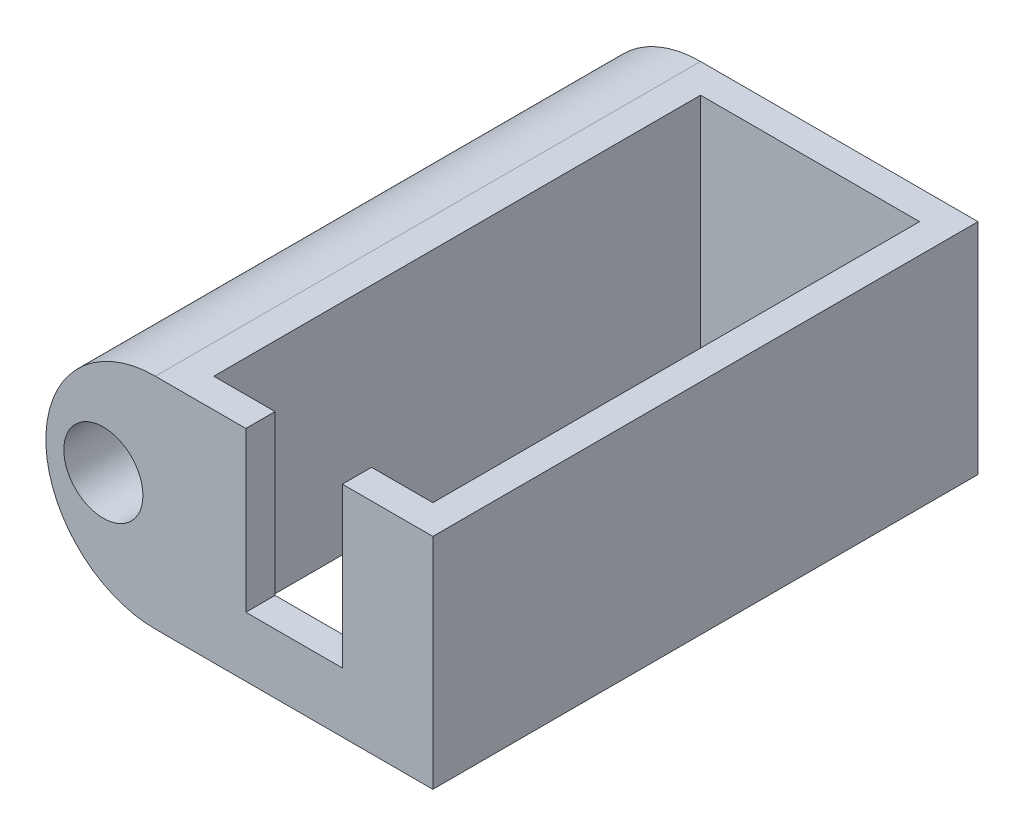
from build123d import *

# Parameters (mm, degrees)
SKETCH1_W           = 11.4
SKETCH1_H           = 22.4
SKETCH1_W_2         = 9
SKETCH1_H_2         = 20
BOSS_EXTRUDE1_DEPTH = 9
CUT_EXTRUDE1_REACH  = 24.4
SKETCH2_W           = 3.96584196
SKETCH2_H           = 6.540682608
SKETCH3_R           = 1.625
BOSS_EXTRUDE2_DEPTH = 22.4
CUT_EXTRUDE2_START  = -4
SKETCH4_R           = 1
CUT_EXTRUDE2_DEPTH  = 10
SKETCH5_R           = 1.55
SKETCH5_R_2         = 1.001932819
BOSS_EXTRUDE3_DEPTH = 1


with BuildPart() as part:
    # Sketch1 → Boss-Extrude1 (new body)
    with BuildSketch(Plane(origin=(0, 0, 0), x_dir=(1, 0, 0), z_dir=(0, 1, 0))):
        with Locations((4.5, 10)):
            Rectangle(SKETCH1_W, SKETCH1_H)
        with Locations((4.5, 10)):
            Rectangle(SKETCH1_W_2, SKETCH1_H_2, mode=Mode.SUBTRACT)
    extrude(amount=BOSS_EXTRUDE1_DEPTH)

    # Sketch2 → Cut-Extrude1 (cut, up to next)
    with BuildSketch(Plane.XY.offset(1.2), mode=Mode.PRIVATE) as cut_extrude1_sk1:
        with Locations((4.5, 5.729658696)):
            Rectangle(SKETCH2_W, SKETCH2_H)
    cut_extrude1_tool1 = extrude(cut_extrude1_sk1.sketch, amount=-CUT_EXTRUDE1_REACH, mode=Mode.PRIVATE) & part.part
    add(cut_extrude1_tool1.solids().sort_by_distance((4.5, 5.729659, 1.2))[0], mode=Mode.SUBTRACT)

    # Sketch3 → Boss-Extrude2 (add)
    with BuildSketch(Plane.XY.offset(1.2)):
        with BuildLine():
            Line((-1.2, 9), (-1.2, 0))
            ThreePointArc((-1.2, 0), (-5.7, 4.5), (-1.2, 9))
        make_face()
        with Locations((-3.337644254, 4.5)):
            Circle(SKETCH3_R, mode=Mode.SUBTRACT)
    extrude(amount=-BOSS_EXTRUDE2_DEPTH)

    # Sketch4 → Cut-Extrude2 (cut)
    with BuildSketch(Plane(origin=(0, 0, 0), x_dir=(0, 0, -1), z_dir=(1, 0, 0)).offset(CUT_EXTRUDE2_START)):
        with Locations((9.899176572, 4.5)):
            Circle(SKETCH4_R)
    extrude(amount=-CUT_EXTRUDE2_DEPTH, mode=Mode.SUBTRACT)


with BuildPart() as body_2:
    # Sketch5 → Boss-Extrude3 (new body)
    with BuildSketch(Plane(origin=(0, 0, -21.2), x_dir=(-1, 0, 0), z_dir=(0, 0, -1))):
        with Locations((3.337644254, 4.5)):
            Circle(SKETCH5_R)
        with Locations((3.337644254, 4.5)):
            Circle(SKETCH5_R_2, mode=Mode.SUBTRACT)
    extrude(amount=-BOSS_EXTRUDE3_DEPTH)


solid = Compound([part.part, body_2.part])
